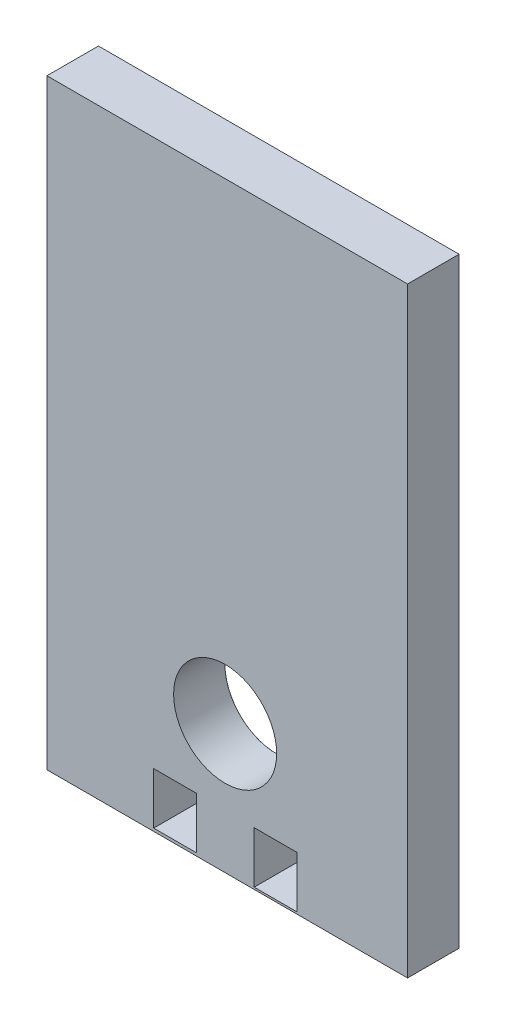
from build123d import *

# Parameters (mm, degrees)
SKETCH1_W                        = 42
SKETCH1_H                        = 70
BOSS_EXTRUDE1_DEPTH              = 6
SKETCH2_W                        = 5
SKETCH2_H                        = 6
CUT_EXTRUDE1_DEPTH               = 9
F_12_0MM_DOWEL_HOLE1_D           = 12
F_12_0MM_DOWEL_HOLE1_DEPTH       = 50
F_12_0MM_DOWEL_HOLE1_CSINK_D     = 12.05
F_12_0MM_DOWEL_HOLE1_CSINK_ANGLE = 90
F_12_0MM_DOWEL_HOLE1_TIP         = 3.605163714


with BuildPart() as part:
    # Sketch1 → Boss-Extrude1 (new body)
    with BuildSketch(Plane.XY):
        with Locations((-9.849777317, 69.889242879)):
            Rectangle(SKETCH1_W, SKETCH1_H)
    extrude(amount=BOSS_EXTRUDE1_DEPTH)

    # Sketch2 → Cut-Extrude1 (cut)
    with BuildSketch(Plane.XY):
        with Locations((-4.211301735, 38.120527714)):
            Rectangle(SKETCH2_W, SKETCH2_H)
        with Locations((-15.91362892, 38.2243844)):
            Rectangle(SKETCH2_W, SKETCH2_H)
    extrude(amount=CUT_EXTRUDE1_DEPTH, mode=Mode.SUBTRACT)

    # Ø12.0mm Dowel Hole1
    with Locations(Plane(origin=(0, 0, 0), x_dir=(-1, 0, 0), z_dir=(0, 0, -1))):
        with Locations((10.096577426, 49.898434055)):
            CounterSinkHole(F_12_0MM_DOWEL_HOLE1_D / 2, F_12_0MM_DOWEL_HOLE1_CSINK_D / 2, depth=F_12_0MM_DOWEL_HOLE1_DEPTH, counter_sink_angle=F_12_0MM_DOWEL_HOLE1_CSINK_ANGLE)
            with Locations((0, 0, -(F_12_0MM_DOWEL_HOLE1_DEPTH + F_12_0MM_DOWEL_HOLE1_TIP / 2))):  # 118° drill point
                Cone(0, F_12_0MM_DOWEL_HOLE1_D / 2, F_12_0MM_DOWEL_HOLE1_TIP, mode=Mode.SUBTRACT)


solid = part.part
